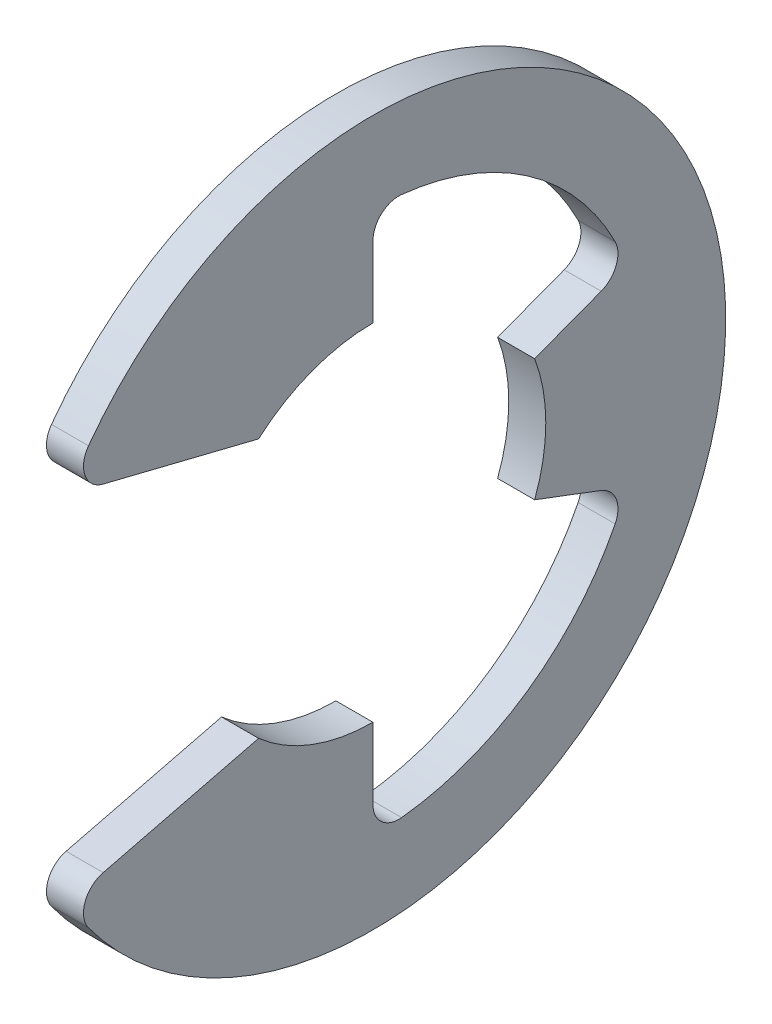
from build123d import *

# Parameters (mm, degrees)
EXTRUDE1_DEPTH = 0.5334
FILLET1_R      = 0.74676


with BuildPart() as part:
    # Sketch1 → Extrude1 (new body, symmetric)
    with BuildSketch(Plane(origin=(0, 0, 0), x_dir=(0, 0, -1), z_dir=(1, 0, 0))):
        with BuildLine():
            Line((-8.788323021, -5.098134804), (-3.292902082, -3.7338))
            ThreePointArc((-3.292902082, -3.7338), (-1.7601302, -4.656866784), (0, -4.9784))
            Line((0, -4.9784), (0, -7.813367742))
            ThreePointArc((0, -7.813367742), (4.442112961, -6.427779392), (7.308736282, -2.762442657))
            Line((7.308736282, -2.762442657), (4.656866784, -1.7601302))
            ThreePointArc((4.656866784, -1.7601302), (4.9784, 0), (4.656866784, 1.7601302))
            Line((4.656866784, 1.7601302), (7.308736282, 2.762442657))
            ThreePointArc((7.308736282, 2.762442657), (4.442112961, 6.427779392), (0, 7.813367742))
            Line((0, 7.813367742), (0, 4.9784))
            ThreePointArc((0, 4.9784), (-1.7601302, 4.656866784), (-3.292902082, 3.7338))
            Line((-3.292902082, 3.7338), (-8.788323021, 5.098134804))
            ThreePointArc((-8.788323021, 5.098134804), (10.16, 0), (-8.788323021, -5.098134804))
        make_face()
    extrude(amount=EXTRUDE1_DEPTH, both=True)

    # Fillet1
    fillet1_edges = [part.edges().sort_by_distance(p)[0] for p in [
        (0, -5.098134804, 8.788323021),
        (0, -7.813367742, 0),
        (0, -2.762442657, -7.308736282),
        (0, 2.762442657, -7.308736282),
        (0, 7.813367742, 0),
        (0, 5.098134804, 8.788323021),
    ]]
    fillet(fillet1_edges, radius=FILLET1_R)


solid = part.part
